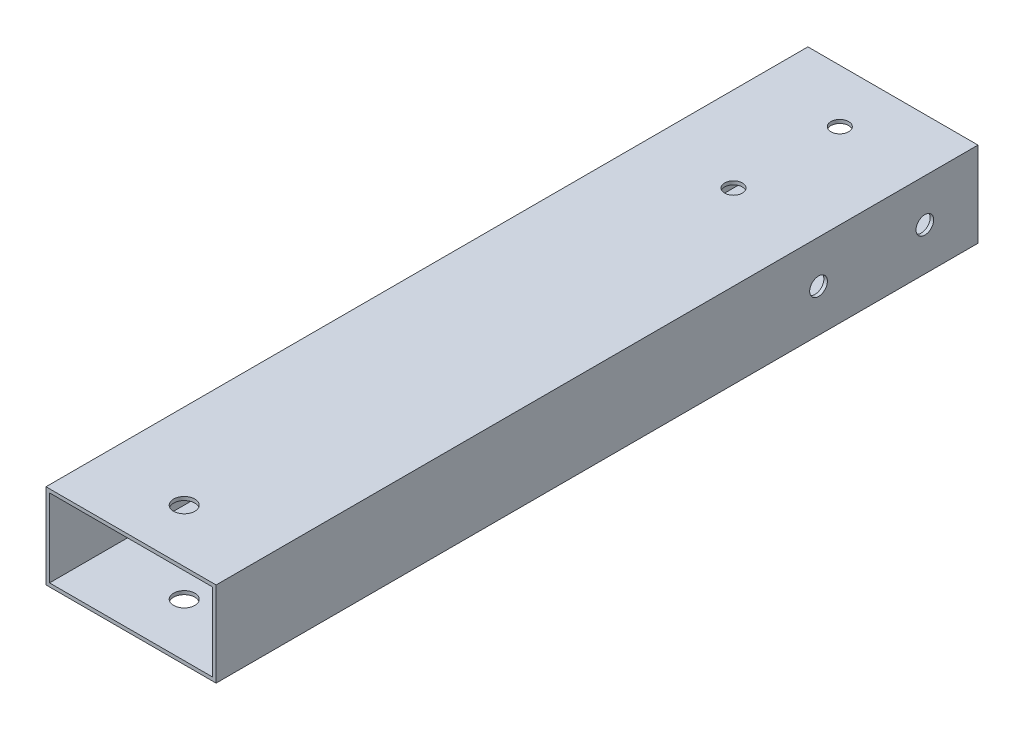
from build123d import *

# Parameters (mm, degrees)
SKETCH2_W           = 48
SKETCH2_H           = 24
SKETCH2_W_2         = 46
SKETCH2_H_2         = 22
BOSS_EXTRUDE1_DEPTH = 240
SKETCH4_R           = 3
CUT_EXTRUDE1_DEPTH  = 240
CUT_EXTRUDE3_DEPTH  = 240
CUT_EXTRUDE4_DEPTH  = 240
SKETCH8_W           = 48
SKETCH8_H           = 25
CUT_EXTRUDE5_DEPTH  = 25


with BuildPart() as part:
    # Sketch2 → Boss-Extrude1 (new body)
    with BuildSketch(Plane.XY):
        Rectangle(SKETCH2_W, SKETCH2_H)
        Rectangle(SKETCH2_W_2, SKETCH2_H_2, mode=Mode.SUBTRACT)
    extrude(amount=BOSS_EXTRUDE1_DEPTH)

    # Sketch4 → Cut-Extrude1 (cut)
    with BuildSketch(Plane.XZ.offset(12)):
        with Locations((0, 200)):
            Circle(SKETCH4_R)
    extrude(amount=-CUT_EXTRUDE1_DEPTH, mode=Mode.SUBTRACT)

    # Sketch5 → Cut-Extrude3 (cut)
    with BuildSketch(Plane.XZ.offset(12)):
        with BuildLine():
            ThreePointArc((2.5, 45), (1.767766953, 46.767766953), (0, 47.5))
            Line((0, 47.5), (0, 42.5))
            ThreePointArc((0, 42.5), (1.767766953, 43.232233047), (2.5, 45))
        make_face()
        with BuildLine():
            Line((0, 42.5), (0, 47.5))
            ThreePointArc((0, 47.5), (-2.5, 45), (0, 42.5))
        make_face()
        with BuildLine():
            ThreePointArc((0, 17.5), (-2.5, 15), (0, 12.5))
            Line((0, 12.5), (0, 17.5))
        make_face()
        with BuildLine():
            Line((0, 17.5), (0, 12.5))
            ThreePointArc((0, 12.5), (1.767766953, 13.232233047), (2.5, 15))
            ThreePointArc((2.5, 15), (1.767766953, 16.767766953), (0, 17.5))
        make_face()
    extrude(amount=-CUT_EXTRUDE3_DEPTH, mode=Mode.SUBTRACT)

    # Sketch7 → Cut-Extrude4 (cut)
    with BuildSketch(Plane(origin=(24, 0, 0), x_dir=(0, 0, -1), z_dir=(1, 0, 0))):
        with BuildLine():
            ThreePointArc((-42.5, 0), (-45, 2.5), (-47.5, 0))
            Line((-47.5, 0), (-42.5, 0))
        make_face()
        with BuildLine():
            Line((-42.5, 0), (-47.5, 0))
            ThreePointArc((-47.5, 0), (-45, -2.5), (-42.5, 0))
        make_face()
        with BuildLine():
            ThreePointArc((-17.5, 0), (-15, -2.5), (-12.5, 0))
            Line((-12.5, 0), (-17.5, 0))
        make_face()
        with BuildLine():
            Line((-17.5, 0), (-12.5, 0))
            ThreePointArc((-12.5, 0), (-15, 2.5), (-17.5, 0))
        make_face()
    extrude(amount=-CUT_EXTRUDE4_DEPTH, mode=Mode.SUBTRACT)

    # Sketch8 → Cut-Extrude5 (cut, through all)
    with BuildSketch(Plane.XZ.offset(12)):
        with Locations((0, 227.5)):
            Rectangle(SKETCH8_W, SKETCH8_H)
    extrude(amount=-CUT_EXTRUDE5_DEPTH, mode=Mode.SUBTRACT)


solid = part.part
